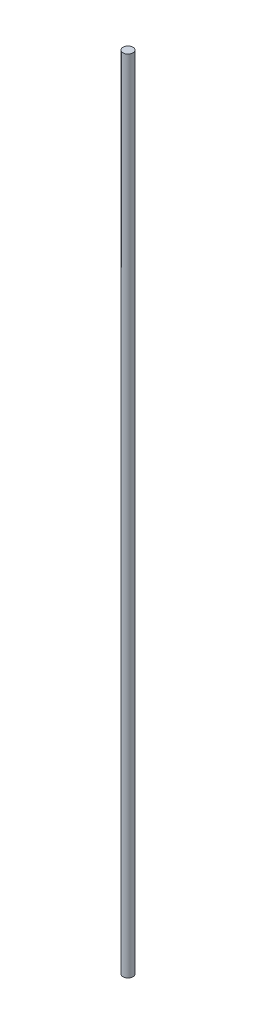
from build123d import *

# Parameters (mm, degrees)
SKETCH1_R           = 5.969
BOSS_EXTRUDE1_DEPTH = 482.6


with BuildPart() as part:
    # Sketch1 → Boss-Extrude1 (new body, symmetric)
    with BuildSketch(Plane(origin=(0, 0, 0), x_dir=(1, 0, 0), z_dir=(0, 1, 0))):
        Circle(SKETCH1_R)
    extrude(amount=BOSS_EXTRUDE1_DEPTH, both=True)


solid = part.part
